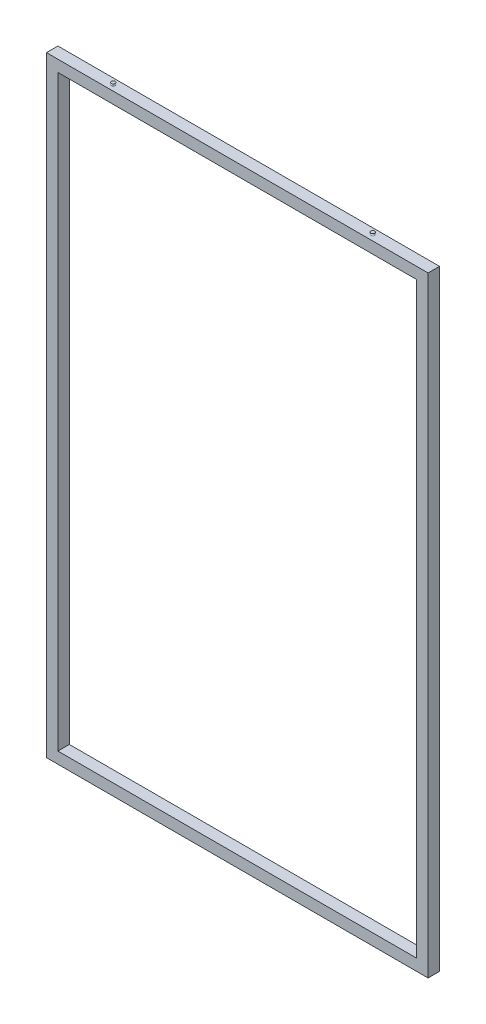
from build123d import *

# Parameters (mm, degrees)
SKETCH1_W           = 1000
SKETCH1_H           = 1600
SKETCH1_W_2         = 940
SKETCH1_H_2         = 1540
BOSS_EXTRUDE1_DEPTH = 15
SKETCH2_W           = 26
SKETCH2_H           = 26


with BuildPart() as part:
    # Sketch1 → Boss-Extrude1 (new body, symmetric)
    with BuildSketch(Plane.XY):
        Rectangle(SKETCH1_W, SKETCH1_H)
        Rectangle(SKETCH1_W_2, SKETCH1_H_2, mode=Mode.SUBTRACT)
    extrude(amount=BOSS_EXTRUDE1_DEPTH, both=True)

    # Cut-Sweep1: sweep along a path in Sketch4
    with BuildLine(Plane.XY) as cut_sweep1_path:
        Line((-485, 785), (-485, -785))
        Line((-485, -785), (485, -785))
        Line((485, -785), (485, 785))
        Line((485, 785), (-485, 785))
    # Sketch2 → Cut-Sweep1 (sweep, cut)
    with BuildSketch(Plane(origin=(0, 0, 0), x_dir=(0, 0, -1), z_dir=(1, 0, 0))):
        with Locations((0, 785)):
            Rectangle(SKETCH2_W, SKETCH2_H)
    sweep(path=cut_sweep1_path.line, transition=Transition.RIGHT, mode=Mode.SUBTRACT)

    # Sketch7 → Revolve1 (revolve)
    with BuildSketch(Plane.XY):
        with BuildLine():
            Line((-340, 800), (-340, 805))
            Line((-340, 805), (-345, 805))
            ThreePointArc((-345, 805), (-342.5, 802.5), (-345, 800))
            Line((-345, 800), (-340, 800))
        make_face()
    revolve1 = revolve(axis=Axis((-340, 795.104340353, 0), (0, 1, 0)))

    # Mirror1: Revolve1 across plane
    add(revolve1.mirror(Plane(origin=(0, 0, 0), x_dir=(0, 0, 1), z_dir=(1, 0, 0))))


solid = part.part
